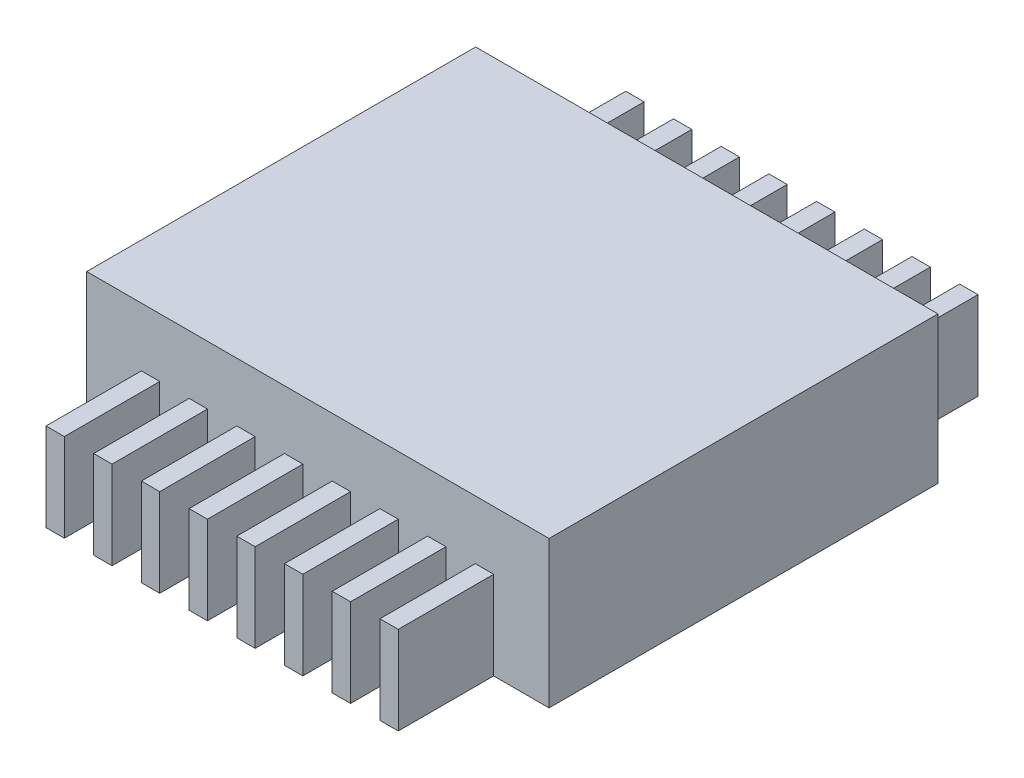
from build123d import *

# Parameters (mm, degrees)
SKETCH1_W               = 6.3
SKETCH1_H               = 5.3
BOSS_EXTRUDE1_DEPTH     = 2
SKETCH2_W               = 0.25
SKETCH2_H               = 1.2
BOSS_EXTRUDE2_DEPTH     = 1.3
LPATTERN1_COUNT         = 8
LPATTERN1_PITCH         = 0.65
MIRROR1_COPY_1_SKETCH_W = 0.25
MIRROR1_COPY_1_SKETCH_H = 1.2
MIRROR1_COPY_1_DEPTH    = 1.3
MIRROR1_COPY_2_SKETCH_W = 0.25
MIRROR1_COPY_2_SKETCH_H = 1.2
MIRROR1_COPY_2_DEPTH    = 1.3
MIRROR1_COPY_3_SKETCH_W = 0.25
MIRROR1_COPY_3_SKETCH_H = 1.2
MIRROR1_COPY_3_DEPTH    = 1.3
MIRROR1_COPY_4_SKETCH_W = 0.25
MIRROR1_COPY_4_SKETCH_H = 1.2
MIRROR1_COPY_4_DEPTH    = 1.3
MIRROR1_COPY_5_SKETCH_W = 0.25
MIRROR1_COPY_5_SKETCH_H = 1.2
MIRROR1_COPY_5_DEPTH    = 1.3
MIRROR1_COPY_6_SKETCH_W = 0.25
MIRROR1_COPY_6_SKETCH_H = 1.2
MIRROR1_COPY_6_DEPTH    = 1.3
MIRROR1_COPY_7_SKETCH_W = 0.25
MIRROR1_COPY_7_SKETCH_H = 1.2
MIRROR1_COPY_7_DEPTH    = 1.3


with BuildPart() as part:
    # Sketch1 → Boss-Extrude1 (new body)
    with BuildSketch(Plane(origin=(0, 0, 0), x_dir=(1, 0, 0), z_dir=(0, 1, 0))):
        Rectangle(SKETCH1_W, SKETCH1_H)
    extrude(amount=BOSS_EXTRUDE1_DEPTH)

    # Sketch2 → Boss-Extrude2 (add)
    with BuildSketch(Plane.XY.offset(2.65)):
        with Locations((-2.28, 0.6)):
            Rectangle(SKETCH2_W, SKETCH2_H)
    boss_extrude2 = extrude(amount=BOSS_EXTRUDE2_DEPTH)

    # LPattern1: Boss-Extrude2 ×8
    with Locations(*[(i * LPATTERN1_PITCH, 0, 0) for i in range(1, LPATTERN1_COUNT)]):
        add(boss_extrude2)

    # Mirror1: Boss-Extrude2 across plane
    add(boss_extrude2.mirror(Plane.XY))

    # Mirror1 copy 1 sketch → Mirror1 copy 1 (add)
    with BuildSketch(Plane(origin=(0.65, 0, -2.65), x_dir=(1, 0, 0), z_dir=(0, 0, -1))):
        with Locations((-2.28, -0.6)):
            Rectangle(MIRROR1_COPY_1_SKETCH_W, MIRROR1_COPY_1_SKETCH_H)
    extrude(amount=MIRROR1_COPY_1_DEPTH)

    # Mirror1 copy 2 sketch → Mirror1 copy 2 (add)
    with BuildSketch(Plane(origin=(1.3, 0, -2.65), x_dir=(1, 0, 0), z_dir=(0, 0, -1))):
        with Locations((-2.28, -0.6)):
            Rectangle(MIRROR1_COPY_2_SKETCH_W, MIRROR1_COPY_2_SKETCH_H)
    extrude(amount=MIRROR1_COPY_2_DEPTH)

    # Mirror1 copy 3 sketch → Mirror1 copy 3 (add)
    with BuildSketch(Plane(origin=(1.95, 0, -2.65), x_dir=(1, 0, 0), z_dir=(0, 0, -1))):
        with Locations((-2.28, -0.6)):
            Rectangle(MIRROR1_COPY_3_SKETCH_W, MIRROR1_COPY_3_SKETCH_H)
    extrude(amount=MIRROR1_COPY_3_DEPTH)

    # Mirror1 copy 4 sketch → Mirror1 copy 4 (add)
    with BuildSketch(Plane(origin=(2.6, 0, -2.65), x_dir=(1, 0, 0), z_dir=(0, 0, -1))):
        with Locations((-2.28, -0.6)):
            Rectangle(MIRROR1_COPY_4_SKETCH_W, MIRROR1_COPY_4_SKETCH_H)
    extrude(amount=MIRROR1_COPY_4_DEPTH)

    # Mirror1 copy 5 sketch → Mirror1 copy 5 (add)
    with BuildSketch(Plane(origin=(3.25, 0, -2.65), x_dir=(1, 0, 0), z_dir=(0, 0, -1))):
        with Locations((-2.28, -0.6)):
            Rectangle(MIRROR1_COPY_5_SKETCH_W, MIRROR1_COPY_5_SKETCH_H)
    extrude(amount=MIRROR1_COPY_5_DEPTH)

    # Mirror1 copy 6 sketch → Mirror1 copy 6 (add)
    with BuildSketch(Plane(origin=(3.9, 0, -2.65), x_dir=(1, 0, 0), z_dir=(0, 0, -1))):
        with Locations((-2.28, -0.6)):
            Rectangle(MIRROR1_COPY_6_SKETCH_W, MIRROR1_COPY_6_SKETCH_H)
    extrude(amount=MIRROR1_COPY_6_DEPTH)

    # Mirror1 copy 7 sketch → Mirror1 copy 7 (add)
    with BuildSketch(Plane(origin=(4.55, 0, -2.65), x_dir=(1, 0, 0), z_dir=(0, 0, -1))):
        with Locations((-2.28, -0.6)):
            Rectangle(MIRROR1_COPY_7_SKETCH_W, MIRROR1_COPY_7_SKETCH_H)
    extrude(amount=MIRROR1_COPY_7_DEPTH)


solid = part.part
